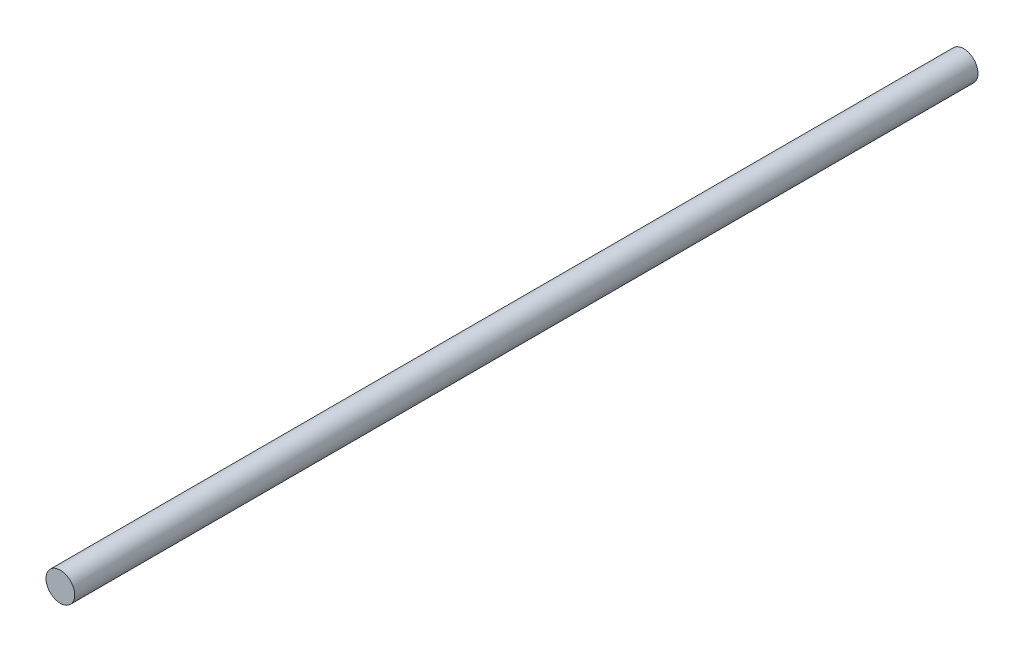
from build123d import *

# Parameters (mm, degrees)
SKETCH_1_R      = 4
EXTRUDE_1_DEPTH = 251.5


with BuildPart() as part:
    # 草图1 → 凸台-拉伸1 (new body)
    with BuildSketch(Plane.XY):
        Circle(SKETCH_1_R)
    extrude(amount=EXTRUDE_1_DEPTH)


solid = part.part
